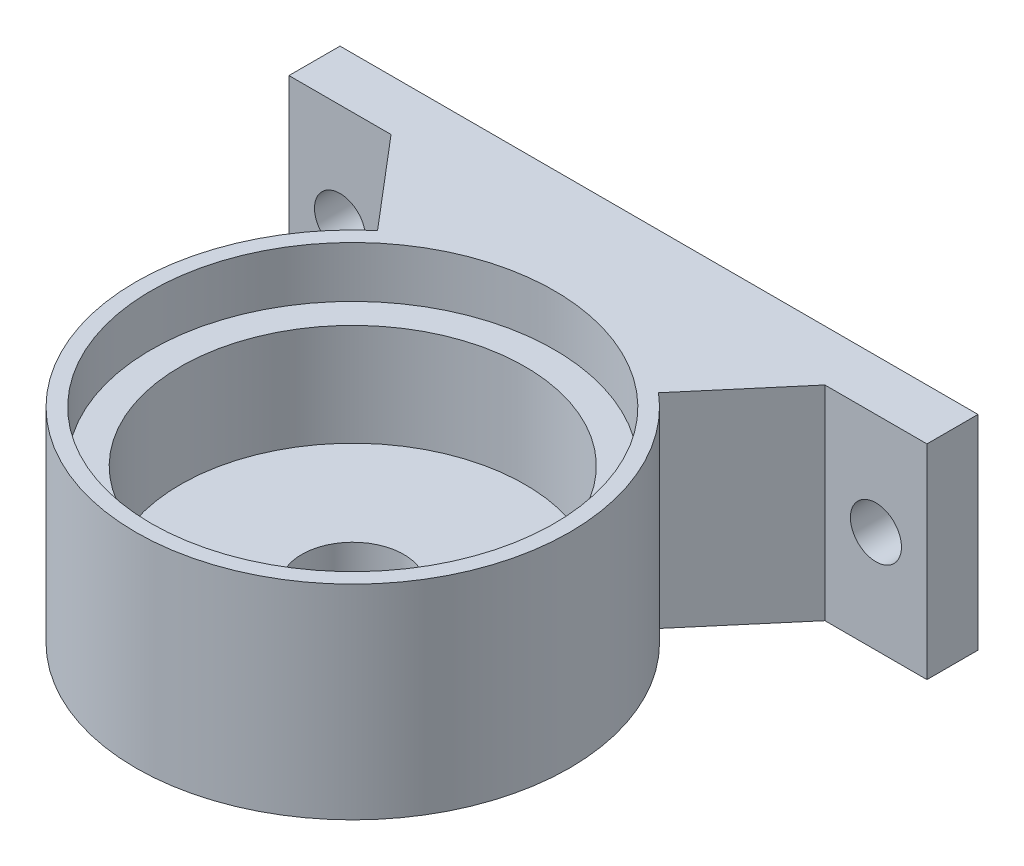
from build123d import *

# Parameters (mm, degrees)
SKETCH_1_R          = 8
SKETCH_1_R_2        = 6.75
EXTRUDE_2_DEPTH     = 6
SKETCH_2_R          = 6.75
SKETCH_2_R_2        = 2
EXTRUDE_3_DEPTH     = 2
SKETCH_3_R          = 8.5
SKETCH_3_R_2        = 7.9
EXTRUDE_4_DEPTH     = 2
SKETCH_4_R          = 8.5
SKETCH_4_R_2        = 8
EXTRUDE_6_DEPTH     = 6
EXTRUDE_8_DEPTH     = 8
SKETCH_7_R          = 1
CUT_EXTRUDE_1_DEPTH = 8


with BuildPart() as part:
    # 草图1 → 凸台-拉伸2 (new body)
    with BuildSketch(Plane(origin=(0, 0, 0), x_dir=(1, 0, 0), z_dir=(0, 1, 0))):
        Circle(SKETCH_1_R)
        Circle(SKETCH_1_R_2, mode=Mode.SUBTRACT)
    extrude(amount=EXTRUDE_2_DEPTH)

    # 草图2 → 凸台-拉伸3 (add)
    with BuildSketch(Plane(origin=(0, 0, 0), x_dir=(1, 0, 0), z_dir=(0, 1, 0))):
        Circle(SKETCH_2_R)
        Circle(SKETCH_2_R_2, mode=Mode.SUBTRACT)
    extrude(amount=EXTRUDE_3_DEPTH)

    # 草图3 → 凸台-拉伸4 (add)
    with BuildSketch(Plane(origin=(0, 6, 0), x_dir=(1, 0, 0), z_dir=(0, 1, 0))):
        Circle(SKETCH_3_R)
        Circle(SKETCH_3_R_2, mode=Mode.SUBTRACT)
    extrude(amount=EXTRUDE_4_DEPTH)

    # 草图4 → 凸台-拉伸6 (add)
    with BuildSketch(Plane.XZ.offset(-6)):
        Circle(SKETCH_4_R)
        Circle(SKETCH_4_R_2, mode=Mode.SUBTRACT)
    extrude(amount=EXTRUDE_6_DEPTH)

    # 草图6 → 凸台-拉伸8 (add)
    with BuildSketch(Plane.XZ):
        with BuildLine():
            Line((-8.5, -10), (-5.505011571, -6.476484201))
            ThreePointArc((-5.505011571, -6.476484201), (0, -8.5), (5.505011571, -6.476484201))
            Line((5.505011571, -6.476484201), (8.5, -10))
            Line((8.5, -10), (12.5, -10))
            Line((12.5, -10), (12.5, -12))
            Line((12.5, -12), (0, -12))
            Line((0, -12), (-12.5, -12))
            Line((-12.5, -12), (-12.5, -10))
            Line((-12.5, -10), (-8.5, -10))
        make_face()
    extrude(amount=-EXTRUDE_8_DEPTH)

    # 草图7 → 切除-拉伸1 (cut)
    with BuildSketch(Plane(origin=(0, 0, -12), x_dir=(-1, 0, 0), z_dir=(0, 0, -1))):
        with Locations((10.5, 4)):
            Circle(SKETCH_7_R)
        with Locations((-10.5, 4)):
            Circle(SKETCH_7_R)
    extrude(amount=-CUT_EXTRUDE_1_DEPTH, mode=Mode.SUBTRACT)


solid = part.part
